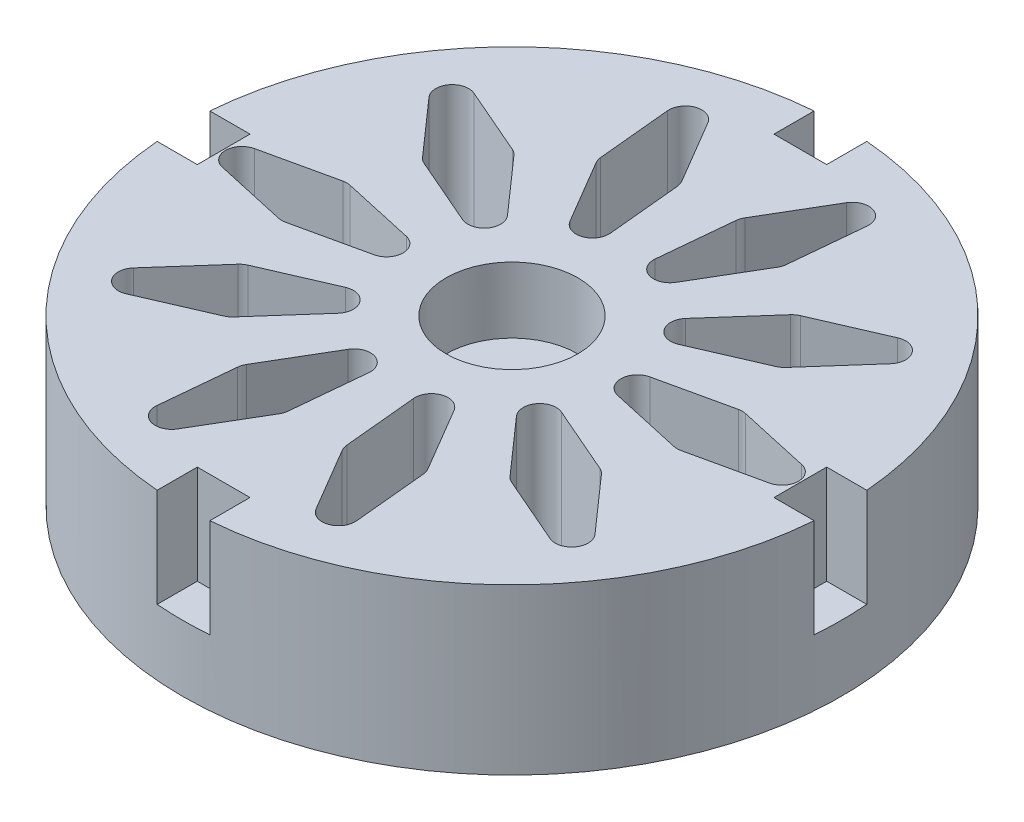
from build123d import *

# Parameters (mm, degrees)
SKETCH_1_R               = 20
SKETCH_1_R_2             = 4
EXTRUDE_1_DEPTH          = 10
SKETCH_4_R               = 20
EXTRUDE_2_DEPTH          = 6
SKETCH_5_R               = 1.6
CUT_EXTRUDE_2_DEPTH      = 5
CUT_EXTRUDE_2_DEPTH_BACK = 7
CUT_EXTRUDE_3_DEPTH      = 1
CUT_EXTRUDE_3_DEPTH_BACK = 11
SKETCH_8_W               = 3.2
SKETCH_8_H               = 5
SKETCH_8_W_2             = 5
SKETCH_8_H_2             = 3.2
CUT_EXTRUDE_4_DEPTH      = 6
SKETCH_9_R               = 3
CUT_EXTRUDE_5_DEPTH      = 2


with BuildPart() as part:
    # Эскиз1 → Бобышка-Вытянуть1 (new body)
    with BuildSketch(Plane(origin=(0, 0, 0), x_dir=(1, 0, 0), z_dir=(0, 1, 0))):
        Circle(SKETCH_1_R)
        Circle(SKETCH_1_R_2, mode=Mode.SUBTRACT)
    extrude(amount=EXTRUDE_1_DEPTH)

    # Эскиз4 → Бобышка-Вытянуть2 (add)
    with BuildSketch(Plane.XZ):
        Circle(SKETCH_4_R)
    extrude(amount=-EXTRUDE_2_DEPTH)

    # Эскиз5 → Вырез-Вытянуть2 (cut, two sides)
    with BuildSketch(Plane(origin=(0, 6, 0), x_dir=(1, 0, 0), z_dir=(0, 1, 0))) as cut_extrude_2_sk:
        Circle(SKETCH_5_R)
    extrude(amount=CUT_EXTRUDE_2_DEPTH, mode=Mode.SUBTRACT)
    extrude(cut_extrude_2_sk.sketch, amount=-CUT_EXTRUDE_2_DEPTH_BACK, mode=Mode.SUBTRACT)

    # Эскиз6 → Вырез-Вытянуть3 (cut, two sides)
    with BuildSketch(Plane.XZ) as cut_extrude_3_sk:
        with BuildLine():
            Line((-7.392841771, 0.97618706), (-11.783069542, 1.951793232))
            ThreePointArc((-11.783069542, 1.951793232), (-12, 1.975606171), (-12.216930458, 1.951793232))
            Line((-12.216930458, 1.951793232), (-16.607158229, 0.97618706))
            ThreePointArc((-16.607158229, 0.97618706), (-17.390227771, 0), (-16.607158229, -0.97618706))
            Line((-16.607158229, -0.97618706), (-12.216930458, -1.951793232))
            ThreePointArc((-12.216930458, -1.951793232), (-12, -1.975606171), (-11.783069542, -1.951793232))
            Line((-11.783069542, -1.951793232), (-7.392841771, -0.97618706))
            ThreePointArc((-7.392841771, -0.97618706), (-6.609772229, 0), (-7.392841771, 0.97618706))
        make_face()
        with BuildLine():
            Line((-5.407146272, 5.135155287), (-8.385468228, 8.504948397))
            ThreePointArc((-8.385468228, 8.504948397), (-8.546971761, 8.651721994), (-8.736469082, 8.759965445))
            Line((-8.736469082, 8.759965445), (-12.861684878, 10.551194611))
            ThreePointArc((-12.861684878, 10.551194611), (-14.068989803, 10.221719418), (-14.009261593, 8.971690768))
            Line((-14.009261593, 8.971690768), (-11.030939637, 5.601897658))
            ThreePointArc((-11.030939637, 5.601897658), (-10.869436104, 5.455124061), (-10.679938783, 5.34688061))
            Line((-10.679938783, 5.34688061), (-6.554722987, 3.555651444))
            ThreePointArc((-6.554722987, 3.555651444), (-5.347418062, 3.885126637), (-5.407146272, 5.135155287))
        make_face()
        with BuildLine():
            Line((-1.356104679, 7.332668731), (-1.784903063, 11.809502348))
            ThreePointArc((-1.784903063, 11.809502348), (-1.82929081, 12.023174077), (-1.918973459, 12.222128599))
            Line((-1.918973459, 12.222128599), (-4.203485056, 16.096004442))
            ThreePointArc((-4.203485056, 16.096004442), (-5.373875917, 16.539089442), (-6.060303186, 15.49268766))
            Line((-6.060303186, 15.49268766), (-5.631504802, 11.015854043))
            ThreePointArc((-5.631504802, 11.015854043), (-5.587117055, 10.802182314), (-5.497434406, 10.603227792))
            Line((-5.497434406, 10.603227792), (-3.212922809, 6.729351949))
            ThreePointArc((-3.212922809, 6.729351949), (-2.042531948, 6.286266949), (-1.356104679, 7.332668731))
        make_face()
        with BuildLine():
            Line((3.212922809, 6.729351949), (5.497434406, 10.603227792))
            ThreePointArc((5.497434406, 10.603227792), (5.587117055, 10.802182314), (5.631504802, 11.015854043))
            Line((5.631504802, 11.015854043), (6.060303186, 15.49268766))
            ThreePointArc((6.060303186, 15.49268766), (5.373875917, 16.539089442), (4.203485056, 16.096004442))
            Line((4.203485056, 16.096004442), (1.918973459, 12.222128599))
            ThreePointArc((1.918973459, 12.222128599), (1.82929081, 12.023174077), (1.784903063, 11.809502348))
            Line((1.784903063, 11.809502348), (1.356104679, 7.332668731))
            ThreePointArc((1.356104679, 7.332668731), (2.042531948, 6.286266949), (3.212922809, 6.729351949))
        make_face()
        with BuildLine():
            Line((6.554722987, 3.555651444), (10.679938783, 5.34688061))
            ThreePointArc((10.679938783, 5.34688061), (10.869436104, 5.455124061), (11.030939637, 5.601897658))
            Line((11.030939637, 5.601897658), (14.009261593, 8.971690768))
            ThreePointArc((14.009261593, 8.971690768), (14.068989803, 10.221719418), (12.861684878, 10.551194611))
            Line((12.861684878, 10.551194611), (8.736469082, 8.759965445))
            ThreePointArc((8.736469082, 8.759965445), (8.546971761, 8.651721994), (8.385468228, 8.504948397))
            Line((8.385468228, 8.504948397), (5.407146272, 5.135155287))
            ThreePointArc((5.407146272, 5.135155287), (5.347418062, 3.885126637), (6.554722987, 3.555651444))
        make_face()
        with BuildLine():
            Line((7.392841771, -0.97618706), (11.783069542, -1.951793232))
            ThreePointArc((11.783069542, -1.951793232), (12, -1.975606171), (12.216930458, -1.951793232))
            Line((12.216930458, -1.951793232), (16.607158229, -0.97618706))
            ThreePointArc((16.607158229, -0.97618706), (17.390227771, 0), (16.607158229, 0.97618706))
            Line((16.607158229, 0.97618706), (12.216930458, 1.951793232))
            ThreePointArc((12.216930458, 1.951793232), (12, 1.975606171), (11.783069542, 1.951793232))
            Line((11.783069542, 1.951793232), (7.392841771, 0.97618706))
            ThreePointArc((7.392841771, 0.97618706), (6.609772229, 0), (7.392841771, -0.97618706))
        make_face()
        with BuildLine():
            Line((5.407146272, -5.135155287), (8.385468228, -8.504948397))
            ThreePointArc((8.385468228, -8.504948397), (8.546971761, -8.651721994), (8.736469082, -8.759965445))
            Line((8.736469082, -8.759965445), (12.861684878, -10.551194611))
            ThreePointArc((12.861684878, -10.551194611), (14.068989803, -10.221719418), (14.009261593, -8.971690768))
            Line((14.009261593, -8.971690768), (11.030939637, -5.601897658))
            ThreePointArc((11.030939637, -5.601897658), (10.869436104, -5.455124061), (10.679938783, -5.34688061))
            Line((10.679938783, -5.34688061), (6.554722987, -3.555651444))
            ThreePointArc((6.554722987, -3.555651444), (5.347418062, -3.885126637), (5.407146272, -5.135155287))
        make_face()
        with BuildLine():
            Line((1.356104679, -7.332668731), (1.784903063, -11.809502348))
            ThreePointArc((1.784903063, -11.809502348), (1.82929081, -12.023174077), (1.918973459, -12.222128599))
            Line((1.918973459, -12.222128599), (4.203485056, -16.096004442))
            ThreePointArc((4.203485056, -16.096004442), (5.373875917, -16.539089442), (6.060303186, -15.49268766))
            Line((6.060303186, -15.49268766), (5.631504802, -11.015854043))
            ThreePointArc((5.631504802, -11.015854043), (5.587117055, -10.802182314), (5.497434406, -10.603227792))
            Line((5.497434406, -10.603227792), (3.212922809, -6.729351949))
            ThreePointArc((3.212922809, -6.729351949), (2.042531948, -6.286266949), (1.356104679, -7.332668731))
        make_face()
        with BuildLine():
            Line((-3.212922809, -6.729351949), (-5.497434406, -10.603227792))
            ThreePointArc((-5.497434406, -10.603227792), (-5.587117055, -10.802182314), (-5.631504802, -11.015854043))
            Line((-5.631504802, -11.015854043), (-6.060303186, -15.49268766))
            ThreePointArc((-6.060303186, -15.49268766), (-5.373875917, -16.539089442), (-4.203485056, -16.096004442))
            Line((-4.203485056, -16.096004442), (-1.918973459, -12.222128599))
            ThreePointArc((-1.918973459, -12.222128599), (-1.82929081, -12.023174077), (-1.784903063, -11.809502348))
            Line((-1.784903063, -11.809502348), (-1.356104679, -7.332668731))
            ThreePointArc((-1.356104679, -7.332668731), (-2.042531948, -6.286266949), (-3.212922809, -6.729351949))
        make_face()
        with BuildLine():
            Line((-6.554722987, -3.555651444), (-10.679938783, -5.34688061))
            ThreePointArc((-10.679938783, -5.34688061), (-10.869436104, -5.455124061), (-11.030939637, -5.601897658))
            Line((-11.030939637, -5.601897658), (-14.009261593, -8.971690768))
            ThreePointArc((-14.009261593, -8.971690768), (-14.068989803, -10.221719418), (-12.861684878, -10.551194611))
            Line((-12.861684878, -10.551194611), (-8.736469082, -8.759965445))
            ThreePointArc((-8.736469082, -8.759965445), (-8.546971761, -8.651721994), (-8.385468228, -8.504948397))
            Line((-8.385468228, -8.504948397), (-5.407146272, -5.135155287))
            ThreePointArc((-5.407146272, -5.135155287), (-5.347418062, -3.885126637), (-6.554722987, -3.555651444))
        make_face()
    extrude(amount=CUT_EXTRUDE_3_DEPTH, mode=Mode.SUBTRACT)
    extrude(cut_extrude_3_sk.sketch, amount=-CUT_EXTRUDE_3_DEPTH_BACK, mode=Mode.SUBTRACT)

    # Эскиз8 → Вырез-Вытянуть4 (cut)
    with BuildSketch(Plane(origin=(0, 10, 0), x_dir=(1, 0, 0), z_dir=(0, 1, 0))):
        with Locations((0, 20)):
            Rectangle(SKETCH_8_W, SKETCH_8_H)
        with Locations((-20, 0)):
            Rectangle(SKETCH_8_W_2, SKETCH_8_H_2)
        with Locations((20, 0)):
            Rectangle(SKETCH_8_W_2, SKETCH_8_H_2)
        with Locations((0, -20)):
            Rectangle(SKETCH_8_W, SKETCH_8_H)
    extrude(amount=-CUT_EXTRUDE_4_DEPTH, mode=Mode.SUBTRACT)

    # Эскиз9 → Вырез-Вытянуть5 (cut)
    with BuildSketch(Plane.XZ):
        Circle(SKETCH_9_R)
    extrude(amount=-CUT_EXTRUDE_5_DEPTH, mode=Mode.SUBTRACT)


solid = part.part
